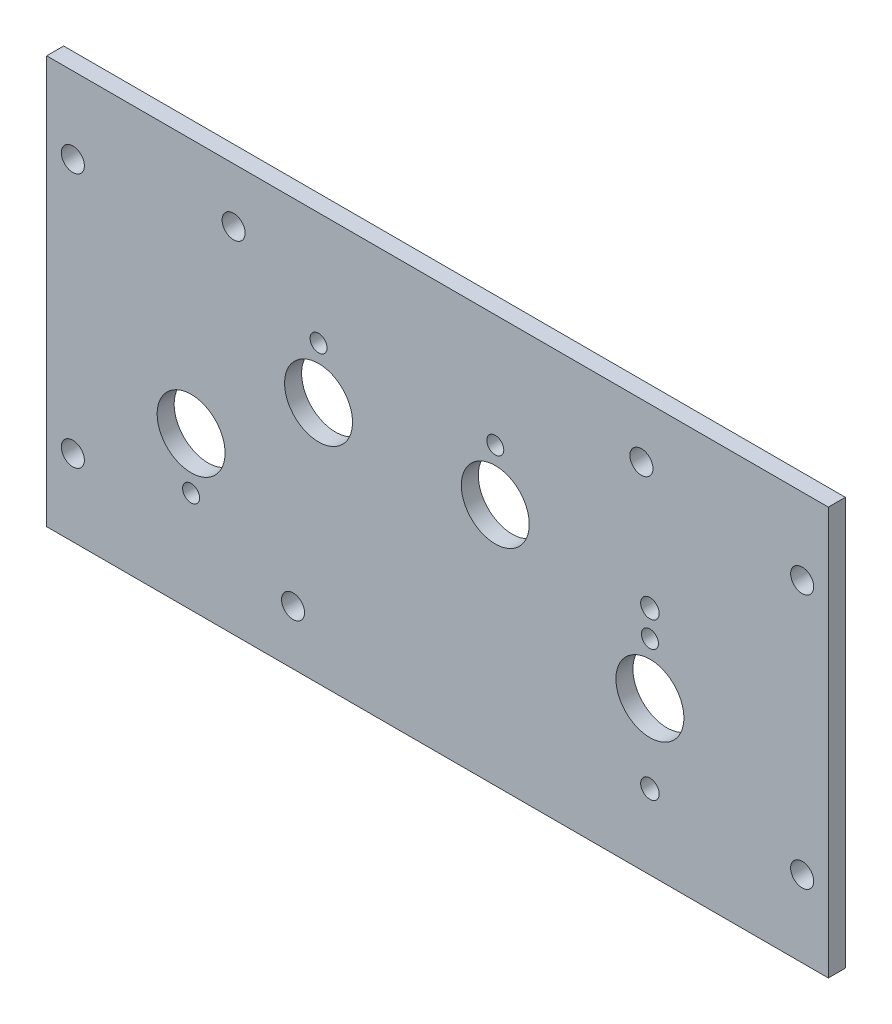
from build123d import *

# Parameters (mm, degrees)
SKETCH1_W                    = 146.05
SKETCH1_H                    = 76.2
BOSS_EXTRUDE1_DEPTH          = 3.175
F_1_8_0_125_DIAMETER_HOLE1_D = 3.175
F_1_2_0_5_DIAMETER_HOLE1_D   = 12.7
F_6_CLEARANCE_HOLE1_D        = 4.3053
F_4_CLEARANCE_HOLE1_D        = 3.4544


with BuildPart() as part:
    # Sketch1 → Boss-Extrude1 (new body)
    with BuildSketch(Plane.XY):
        with Locations((-73.025, 38.1)):
            Rectangle(SKETCH1_W, SKETCH1_H)
    extrude(amount=-BOSS_EXTRUDE1_DEPTH)

    # 1/8 (0.125) Diameter Hole1 (through all)
    with Locations(Plane(origin=(0, 0, -3.175), x_dir=(-1, 0, 0), z_dir=(0, 0, -1))):
        with Locations((95.25, 55.118), (119.0625, 18.923), (62.23, 55.118), (33.3375, 38.227)):
            Hole(F_1_8_0_125_DIAMETER_HOLE1_D / 2)

    # 1/2 (0.5) Diameter Hole1 (through all)
    with Locations(Plane(origin=(0, 0, -3.175), x_dir=(-1, 0, 0), z_dir=(0, 0, -1))):
        with Locations((95.25, 45.466), (119.0625, 28.575), (62.23, 45.466), (33.3375, 28.575)):
            Hole(F_1_2_0_5_DIAMETER_HOLE1_D / 2)

    # #6 Clearance Hole1 (through all)
    with Locations(Plane(origin=(0, 0, -3.175), x_dir=(-1, 0, 0), z_dir=(0, 0, -1))):
        with Locations((141.1605, 61.9125), (141.1605, 14.2875), (4.8895, 61.9125), (4.8895, 14.2875), (111.125, 66.04), (100.01504, 10.16), (34.925, 66.04)):
            Hole(F_6_CLEARANCE_HOLE1_D / 2)

    # #4 Clearance Hole1 (through all)
    with Locations(Plane(origin=(0, 0, -3.175), x_dir=(-1, 0, 0), z_dir=(0, 0, -1))):
        with Locations((33.3375, 43.18), (33.3375, 13.97)):
            Hole(F_4_CLEARANCE_HOLE1_D / 2)


solid = part.part
